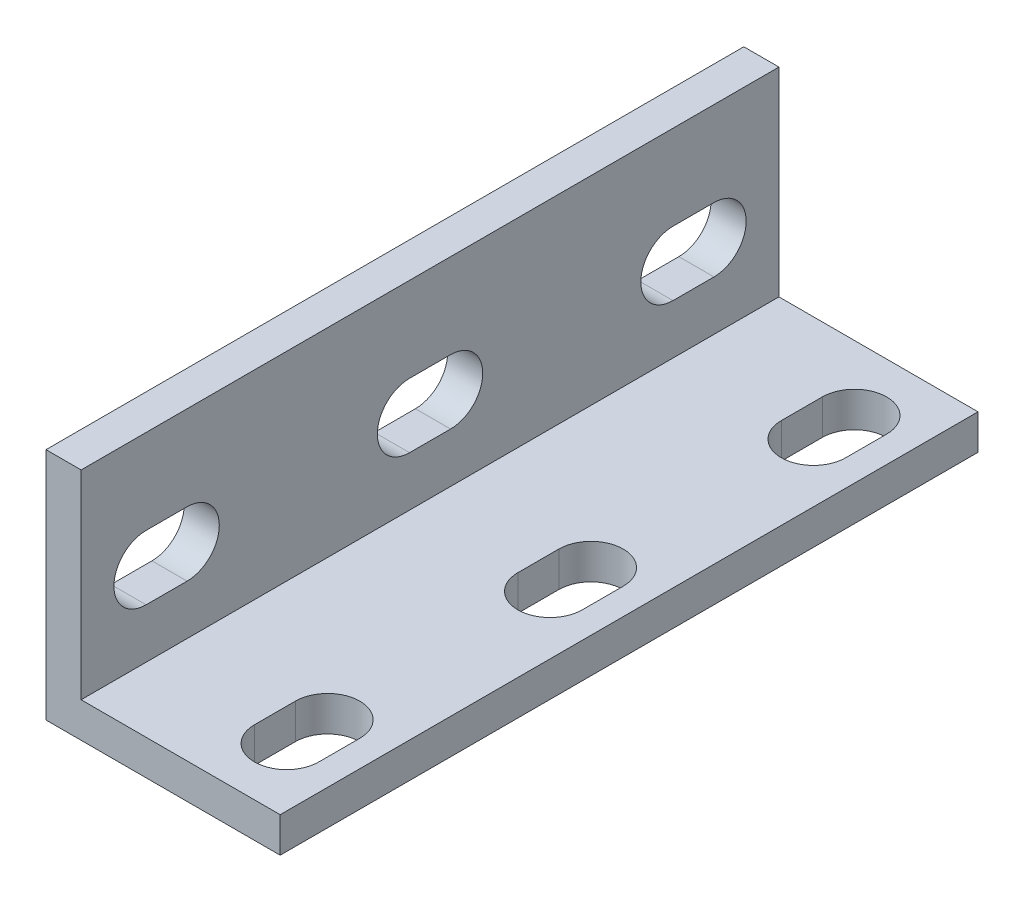
from build123d import *

# Parameters (mm, degrees)
EXTRUDE_THIN1_DEPTH = 59.6
CUT_EXTRUDE1_DEPTH  = 4
CUT_EXTRUDE2_DEPTH  = 4


with BuildPart() as part:
    # Sketch1 → Extrude-Thin1 (new body)
    with BuildSketch(Plane.XY):
        Polygon((0, 20), (0, 0), (20, 0), (20, 3), (3, 3), (3, 20), align=None)
    extrude(amount=EXTRUDE_THIN1_DEPTH)

    # Sketch2 → Cut-Extrude1 (cut, through all)
    with BuildSketch(Plane(origin=(3, 0, 0), x_dir=(0, 0, -1), z_dir=(1, 0, 0))):
        with BuildLine():
            Line((-50.55, 7.25), (-54.05, 7.25))
            ThreePointArc((-54.05, 7.25), (-56.8, 10), (-54.05, 12.75))
            Line((-54.05, 12.75), (-50.55, 12.75))
            ThreePointArc((-50.55, 12.75), (-47.8, 10), (-50.55, 7.25))
        make_face()
        with BuildLine():
            Line((-9.05, 7.25), (-5.55, 7.25))
            ThreePointArc((-5.55, 7.25), (-2.8, 10), (-5.55, 12.75))
            Line((-5.55, 12.75), (-9.05, 12.75))
            ThreePointArc((-9.05, 12.75), (-11.8, 10), (-9.05, 7.25))
        make_face()
        with BuildLine():
            Line((-28.05, 7.25), (-31.55, 7.25))
            ThreePointArc((-31.55, 7.25), (-34.3, 10), (-31.55, 12.75))
            Line((-31.55, 12.75), (-28.05, 12.75))
            ThreePointArc((-28.05, 12.75), (-25.3, 10), (-28.05, 7.25))
        make_face()
    extrude(amount=-CUT_EXTRUDE1_DEPTH, mode=Mode.SUBTRACT)

    # Sketch3 → Cut-Extrude2 (cut, through all)
    with BuildSketch(Plane(origin=(0, 3, 0), x_dir=(1, 0, 0), z_dir=(0, 1, 0))):
        with BuildLine():
            Line((12.25, -54.05), (12.25, -50.55))
            ThreePointArc((12.25, -50.55), (15, -47.8), (17.75, -50.55))
            Line((17.75, -50.55), (17.75, -54.05))
            ThreePointArc((17.75, -54.05), (15, -56.8), (12.25, -54.05))
        make_face()
        with BuildLine():
            Line((12.25, -5.55), (12.25, -9.05))
            ThreePointArc((12.25, -9.05), (15, -11.8), (17.75, -9.05))
            Line((17.75, -9.05), (17.75, -5.55))
            ThreePointArc((17.75, -5.55), (15, -2.8), (12.25, -5.55))
        make_face()
        with BuildLine():
            Line((17.75, -28.05), (17.75, -31.55))
            ThreePointArc((17.75, -31.55), (15, -34.3), (12.25, -31.55))
            Line((12.25, -31.55), (12.25, -28.05))
            ThreePointArc((12.25, -28.05), (15, -25.3), (17.75, -28.05))
        make_face()
    extrude(amount=-CUT_EXTRUDE2_DEPTH, mode=Mode.SUBTRACT)


solid = part.part
